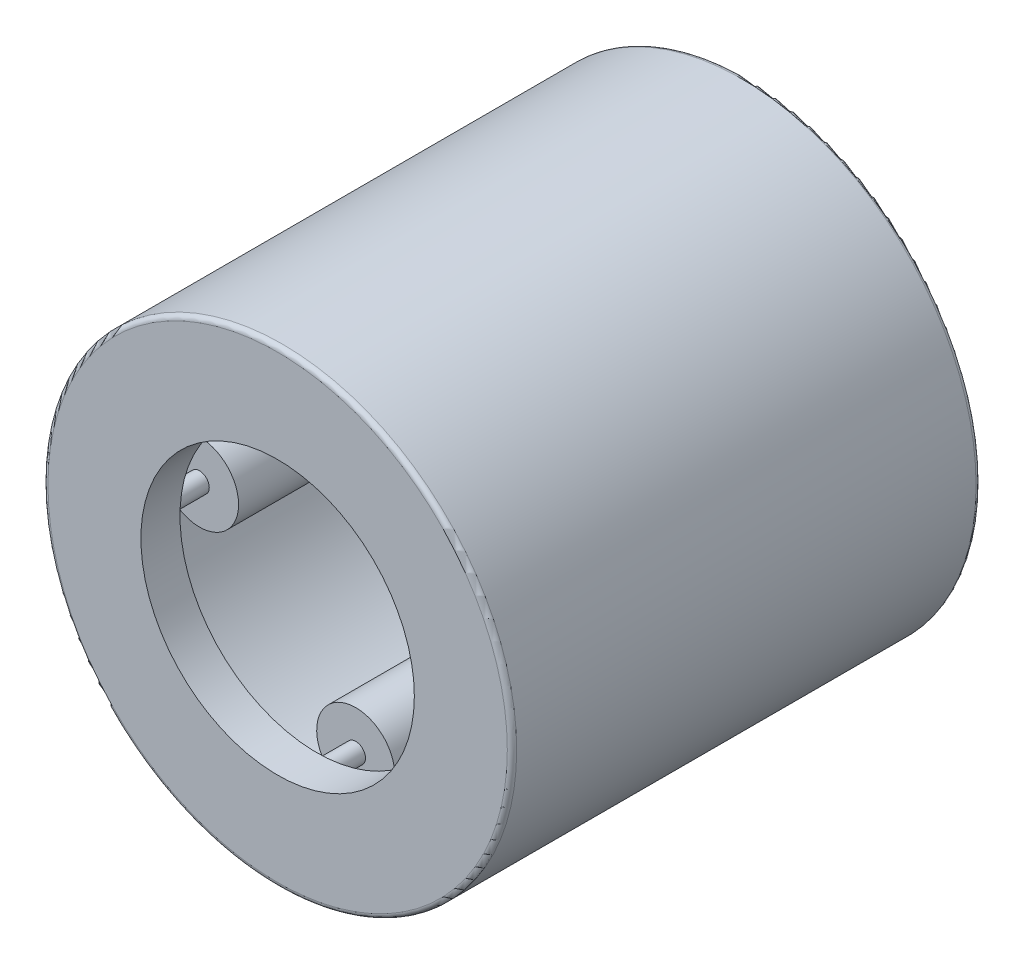
from build123d import *

# Parameters (mm, degrees)
SKETCH2_W         = 4.233333334
SKETCH2_H         = 0.396875
SKETCH3_W         = 5.291666666
SKETCH3_H         = 0.132291666
CIRPATTERN1_COUNT = 4
CIRPATTERN1_ANGLE = 270
FILLET1_R         = 0.0635


with BuildPart() as part:
    # Sketch1 → Revolve1 (revolve)
    with BuildSketch(Plane(origin=(0, 0, 0), x_dir=(0, 0, -1), z_dir=(1, 0, 0))):
        Polygon((-3.175, 3.175), (3.175, 3.175), (3.175, 1.852083333), (2.645833333, 1.852083333), (2.645833333, 2.645833333), (-2.645833333, 2.645833333), (-2.645833333, 1.852083333), (-3.175, 1.852083333), align=None)
    revolve(axis=Axis((0, 0, 3.175), (0, 0, -1)))

    # Fillet1
    fillet1_edges = [part.edges().sort_by_distance(p)[0] for p in [
        (0, -3.175, 3.175),
        (0, -3.175, -3.175),
    ]]
    fillet(fillet1_edges, radius=FILLET1_R)


with BuildPart() as body_2:
    # Sketch2 → Revolve2 (revolve)
    with BuildSketch(Plane(origin=(0, 0, 0), x_dir=(0, 0, -1), z_dir=(1, 0, 0))):
        with Locations((0, 2.447395833)):
            Rectangle(SKETCH2_W, SKETCH2_H)
    revolve(axis=Axis((0, 2.116666667, 2.116666667), (0, 0, -1)))


with BuildPart() as body_3:
    # Sketch3 → Revolve3 (revolve)
    with BuildSketch(Plane(origin=(0, 0, 0), x_dir=(0, 0, -1), z_dir=(1, 0, 0))):
        with Locations((0, 2.1828125)):
            Rectangle(SKETCH3_W, SKETCH3_H)
    revolve(axis=Axis((0, 2.116666667, 2.645833333), (0, 0, -1)))


with BuildPart() as cirpattern1_1:
    # CirPattern1: pattern copy
    add(body_2.part.rotate(Axis((0, 0, -3.175), (0, 0, 1)), 1 * CIRPATTERN1_ANGLE / (CIRPATTERN1_COUNT - 1)))


with BuildPart() as cirpattern1_2:
    # CirPattern1: pattern copy
    add(body_2.part.rotate(Axis((0, 0, -3.175), (0, 0, 1)), 2 * CIRPATTERN1_ANGLE / (CIRPATTERN1_COUNT - 1)))


with BuildPart() as cirpattern1_3:
    # CirPattern1: pattern copy
    add(body_2.part.rotate(Axis((0, 0, -3.175), (0, 0, 1)), 3 * CIRPATTERN1_ANGLE / (CIRPATTERN1_COUNT - 1)))


with BuildPart() as cirpattern1_4:
    # CirPattern1: pattern copy
    add(body_3.part.rotate(Axis((0, 0, -3.175), (0, 0, 1)), 1 * CIRPATTERN1_ANGLE / (CIRPATTERN1_COUNT - 1)))


with BuildPart() as cirpattern1_5:
    # CirPattern1: pattern copy
    add(body_3.part.rotate(Axis((0, 0, -3.175), (0, 0, 1)), 2 * CIRPATTERN1_ANGLE / (CIRPATTERN1_COUNT - 1)))


with BuildPart() as cirpattern1_6:
    # CirPattern1: pattern copy
    add(body_3.part.rotate(Axis((0, 0, -3.175), (0, 0, 1)), 3 * CIRPATTERN1_ANGLE / (CIRPATTERN1_COUNT - 1)))


solid = Compound([part.part, body_2.part, body_3.part, cirpattern1_1.part, cirpattern1_2.part, cirpattern1_3.part, cirpattern1_4.part, cirpattern1_5.part, cirpattern1_6.part])
